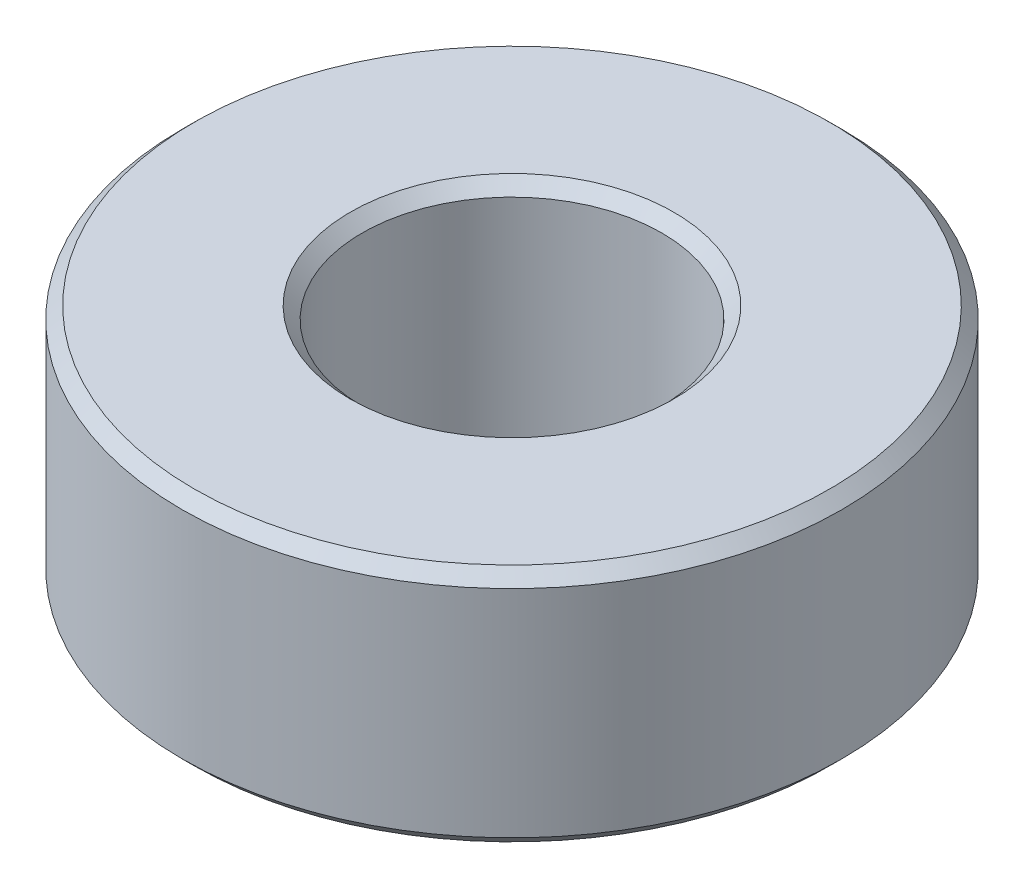
from build123d import *

# Parameters (mm, degrees)
SKETCH1_R           = 5.500000049
SKETCH1_R_2         = 2.499999953
BOSS_EXTRUDE1_DEPTH = 4
CHAMFER1_SIZE       = 0.2


with BuildPart() as part:
    # Sketch1 → Boss-Extrude1 (new body)
    with BuildSketch(Plane(origin=(0, 0, 0), x_dir=(1, 0, 0), z_dir=(0, 1, 0))):
        Circle(SKETCH1_R)
        Circle(SKETCH1_R_2, mode=Mode.SUBTRACT)
    extrude(amount=BOSS_EXTRUDE1_DEPTH)

    # Chamfer1
    chamfer1_edges = [part.edges().sort_by_distance(p)[0] for p in [
        (-5.500000049, 0, 0),
        (-5.500000049, 4, 0),
        (-2.499999953, 0, 0),
        (-2.499999953, 4, 0),
    ]]
    chamfer(chamfer1_edges, length=CHAMFER1_SIZE)


solid = part.part
